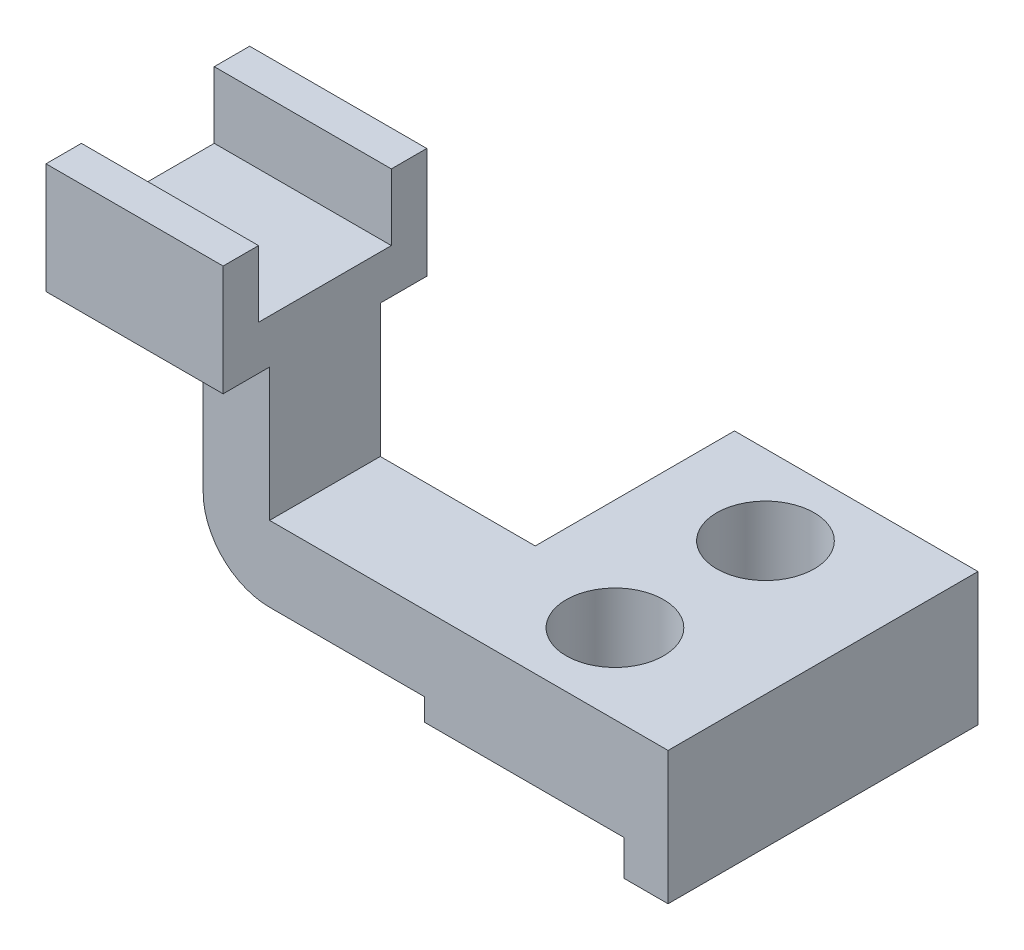
from build123d import *

# Parameters (mm, degrees)
SKETCH2_R           = 11
BOSS_EXTRUDE1_DEPTH = 30
CUT_EXTRUDE1_DEPTH  = 70
BOSS_EXTRUDE3_DEPTH = 40
CUT_EXTRUDE2_DEPTH  = 46
FILLET1_R           = 15


with BuildPart() as part:
    # Sketch2 → Boss-Extrude1 (new body)
    with BuildSketch(Plane(origin=(0, 0, 0), x_dir=(1, 0, 0), z_dir=(0, 1, 0))):
        Polygon((-63.982218383188474, 1.2957443941801692), (-63.98221838318849, -23.70425560581983), (26.017781616811508, -23.70425560581983), (26.017781616811508, 46.295744394180176), (-28.982218383188492, 46.29574439418017), (-28.982218383188492, 1.2957443941801692), align=None)
        with Locations(Location((-3.9822183831884903, -5.704255605819837, 0), (0, 0, 270))):
            Circle(SKETCH2_R, mode=Mode.SUBTRACT)
        with Locations(Location((-3.9822183831884903, 28.295744394180172, 0), (0, 0, 270))):
            Circle(SKETCH2_R, mode=Mode.SUBTRACT)
    extrude(amount=BOSS_EXTRUDE1_DEPTH)

    # Sketch3 → Cut-Extrude1 (cut)
    with BuildSketch(Plane.XY.offset(23.70425560581983)):
        Polygon((-63.98221838318849, 0), (16.01778161681151, 0), (16.017781616811508, 8), (-28.982218383188492, 7.999999999999995), (-28.982218383188492, 12.999999999999995), (-63.982218383188496, 12.999999999999995), align=None)
    extrude(amount=-CUT_EXTRUDE1_DEPTH, mode=Mode.SUBTRACT)

    # 3DSketch1 → Boss-Extrude3 (add)
    with BuildSketch(Plane(origin=(-63.98221838318849, 12.999999999999995, -1.2957443941801692), x_dir=(0, 0.8969047134125312, 0.4422238517520119), z_dir=(-1, 0, 0))):
        Polygon((0, 0), (11.055596293800297, -22.422617835313282), (53.21011782418927, -1.6380968029687248), (57.85346826758539, -11.055596293800305), (80.27608610289867, 0), (76.73829528888258, 7.1752377073002505), (63.28472458769462, 0.5418799310200721), (50.018009035134256, 27.449021333396008), (63.47157973632223, 34.08237910967619), (59.93378892230613, 41.25761681697644), (37.511171086992846, 30.20202052317613), (42.15452153038897, 20.784521032344557), align=None)
    extrude(amount=BOSS_EXTRUDE3_DEPTH)

    # Sketch4 → Cut-Extrude2 (cut)
    with BuildSketch(Plane.XY.offset(23.70425560581983)):
        Polygon((-103.9822183831885, 12.999999999999993), (-78.9822183831885, 13), (-78.9822183831885, 60), (-103.9822183831885, 60), align=None)
    extrude(amount=-CUT_EXTRUDE2_DEPTH, mode=Mode.SUBTRACT)

    # Fillet1
    fillet1_edges = [part.edges().sort_by_distance(p)[0] for p in [
        (-78.9822183831885, 13, 11.204255605819831),
    ]]
    fillet(fillet1_edges, radius=FILLET1_R)


solid = part.part
